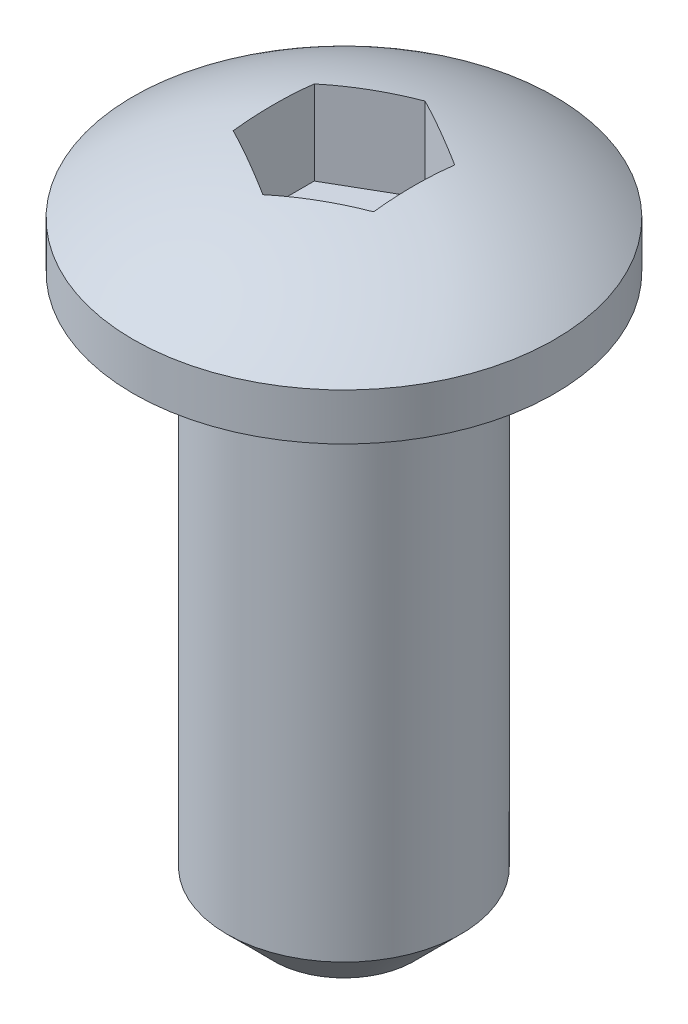
from build123d import *

# Parameters (mm, degrees)
ENL_V_START             = 0.5
ENL_V_MAT_EXTRU_1_DEPTH = 3
CHANFREIN1_SIZE         = 1


with BuildPart() as part:
    # Esquisse1 → Révolution1 (revolve)
    with BuildSketch(Plane.XY, mode=Mode.PRIVATE) as r_volution1_sk:
        with BuildLine():
            Line((0, -12), (0, 2.5))
            ThreePointArc((0, 2.5), (-2.371708245, 2.115124735), (-4.5, 1))
            Line((-4.5, 1), (-4.5, 0))
            Line((-4.5, 0), (-2.5, 0))
            Line((-2.5, 0), (-2.5, -12))
            Line((-2.5, -12), (0, -12))
        make_face()
    revolve(r_volution1_sk.sketch.rotate(Axis((0, 16.1829806, 0), (0, -1, 0)), 270), axis=Axis((0, 16.1829806, 0), (0, -1, 0)))  # turned: the seam where the file's is

    # Esquisse2 → Enlèv. mat.-Extru.1 (cut, through all)
    with BuildSketch(Plane(origin=(0, 0, 0), x_dir=(1, 0, 0), z_dir=(0, 1, 0)).offset(ENL_V_START)):
        Polygon((0, 1.732050808), (-1.5, 0.866025404), (-1.5, -0.866025404), (0, -1.732050808), (1.5, -0.866025404), (1.5, 0.866025404), align=None)
    extrude(amount=ENL_V_MAT_EXTRU_1_DEPTH, mode=Mode.SUBTRACT)

    # Chanfrein1
    chanfrein1_edges = [part.edges().sort_by_distance(p)[0] for p in [
        (0, -12, -2.5),
    ]]
    chamfer(chanfrein1_edges, length=CHANFREIN1_SIZE)


solid = part.part
